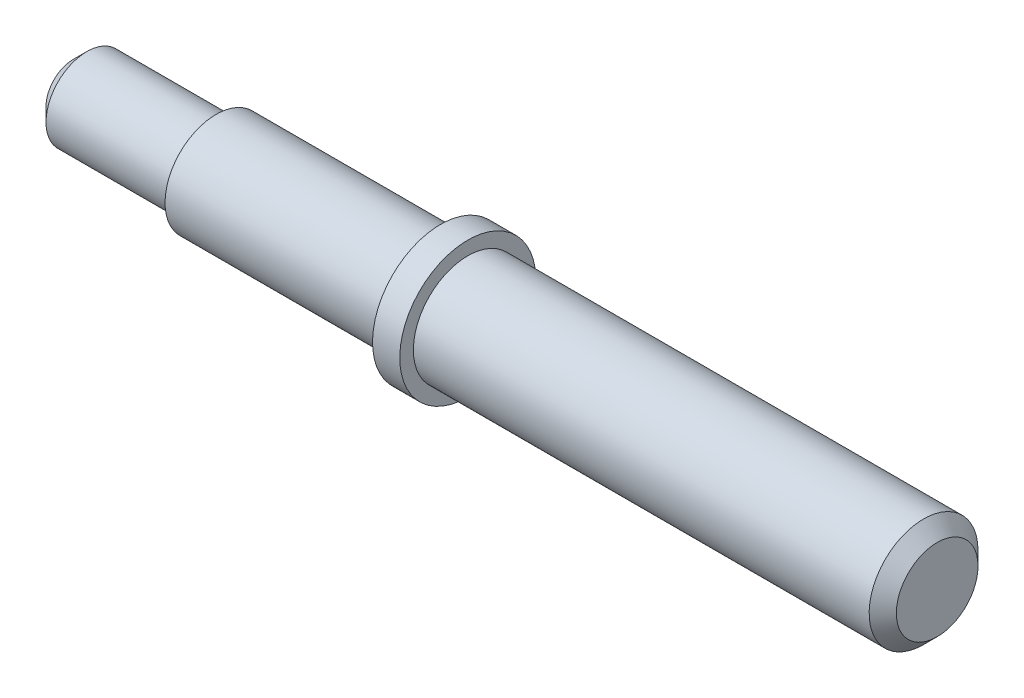
from build123d import *

# Parameters (mm, degrees)
SKIZZE2_R                       = 7.5
SKIZZE2_R_2                     = 6
SCHNITT_LINEAR_AUSTRAGEN2_DEPTH = 21
FASE2_SIZE                      = 2
FASE3_SIZE                      = 2


with BuildPart() as part:
    # Skizze1 → Rotation1 (revolve)
    with BuildSketch(Plane.XY):
        Polygon((0, 0), (-69, 0), (-69, -2), (-73, -2), (-73, 0.5), (-127, 0.5), (-127, 8), (0, 8), align=None)
    revolve(axis=Axis((-127, 8, 0), (1, 0, 0)))

    # Skizze2 → Schnitt-Linear austragen2 (cut)
    with BuildSketch(Plane.ZY.offset(127)):
        with Locations((0, 8)):
            Circle(SKIZZE2_R)
        with Locations((0, 8)):
            Circle(SKIZZE2_R_2, mode=Mode.SUBTRACT)
    extrude(amount=-SCHNITT_LINEAR_AUSTRAGEN2_DEPTH, mode=Mode.SUBTRACT)

    # Fase2
    fase2_edges = [part.edges().sort_by_distance(p)[0] for p in [
        (-127, 8, -6),
    ]]
    chamfer(fase2_edges, length=FASE2_SIZE)

    # Fase3
    fase3_edges = [part.edges().sort_by_distance(p)[0] for p in [
        (0, 16, 0),
    ]]
    chamfer(fase3_edges, length=FASE3_SIZE)


solid = part.part
